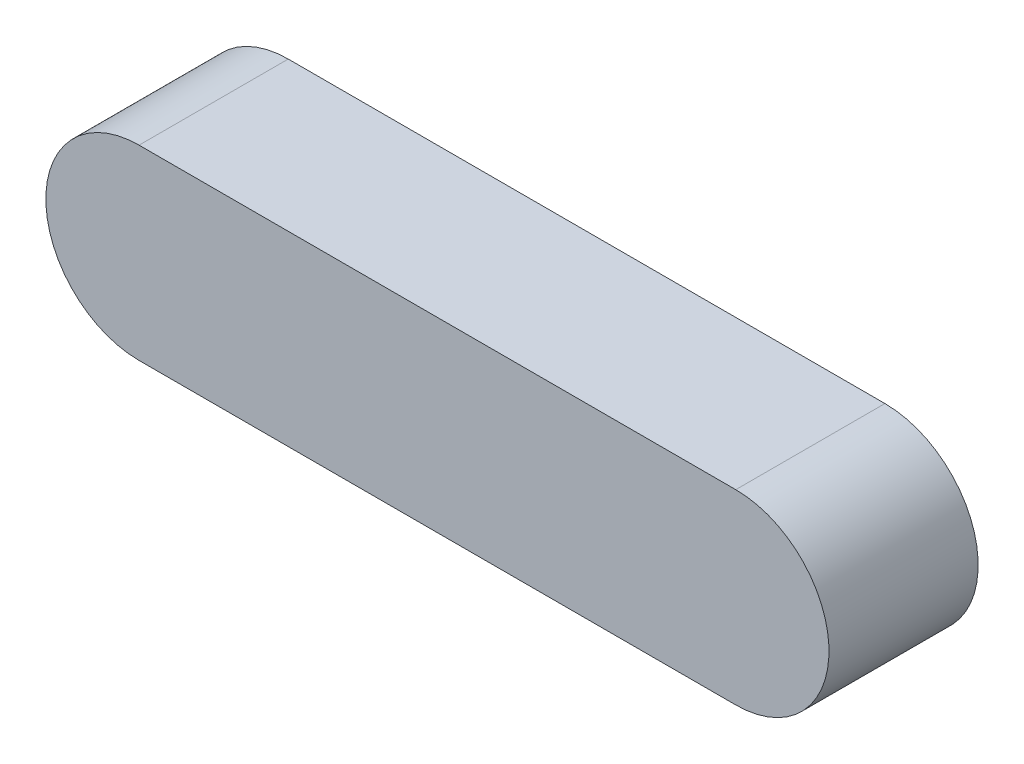
from build123d import *

# Parameters (mm, degrees)
BOSS_EXTRUDE1_DEPTH = 8


with BuildPart() as part:
    # Sketch2 → Boss-Extrude1 (new body)
    with BuildSketch(Plane.XY):
        with BuildLine():
            Line((-11.495327103, 5), (20.504672897, 5))
            ThreePointArc((20.504672897, 5), (25.504672897, 0), (20.504672897, -5))
            Line((20.504672897, -5), (-11.495327103, -5))
            ThreePointArc((-11.495327103, -5), (-16.495327103, 0), (-11.495327103, 5))
        make_face()
    extrude(amount=BOSS_EXTRUDE1_DEPTH)


solid = part.part
